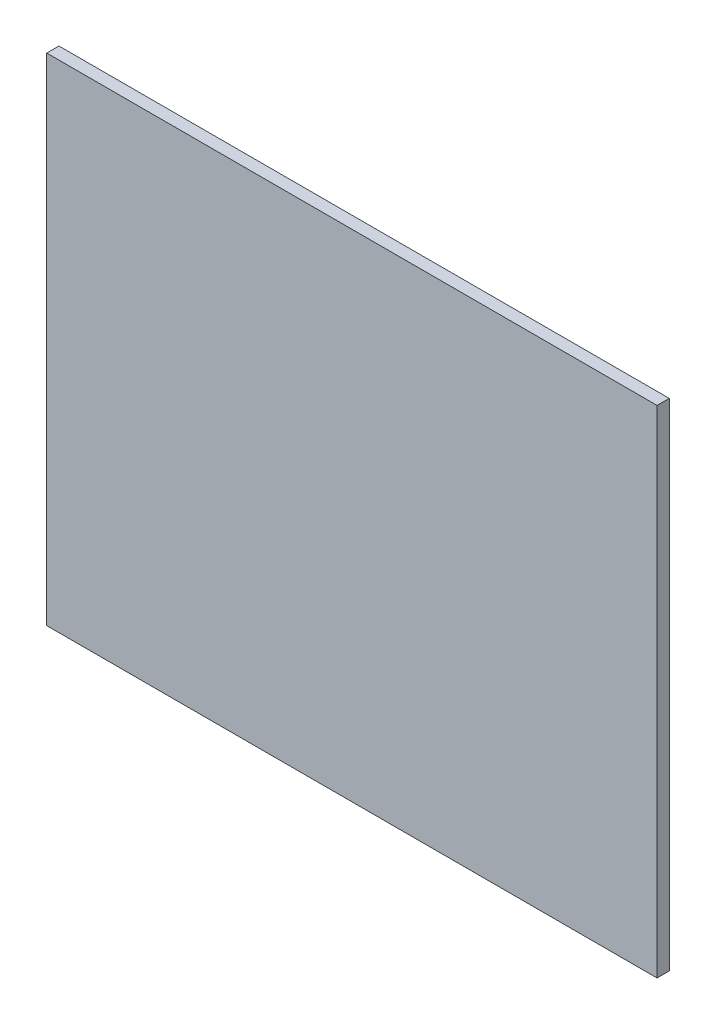
from build123d import *

# Parameters (mm, degrees)
SKETCH1_W           = 80
SKETCH1_H           = 65
BOSS_EXTRUDE1_DEPTH = 1.6


with BuildPart() as part:
    # Sketch1 → Boss-Extrude1 (new body)
    with BuildSketch(Plane.XY):
        with Locations((44.25, 37.5)):
            Rectangle(SKETCH1_W, SKETCH1_H)
    extrude(amount=BOSS_EXTRUDE1_DEPTH)


solid = part.part
